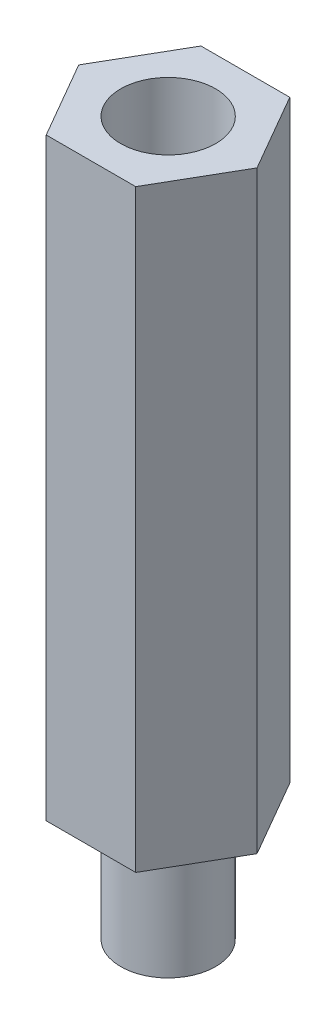
from build123d import *

# Parameters (mm, degrees)
SKETCH_1_R      = 4
EXTRUDE_1_DEPTH = 50
SKETCH_2_R      = 4
EXTRUDE_2_DEPTH = 10


with BuildPart() as part:
    # 草图1 → 凸台-拉伸1 (new body)
    with BuildSketch(Plane(origin=(0, 0, 0), x_dir=(1, 0, 0), z_dir=(0, 1, 0))):
        Polygon((-3.041910015, 3.990808824), (4.434714707, 3.990808824), (8.201955845, -2.534244233), (4.463643484, -9.009191176), (-3.070838793, -9.009191176), (-6.809151154, -2.534244233), align=None)
        with Locations((0.696402346, -2.509191176)):
            Circle(SKETCH_1_R, mode=Mode.SUBTRACT)
    extrude(amount=EXTRUDE_1_DEPTH)


with BuildPart() as body_2:
    # 草图2 → 凸台-拉伸2 (new body)
    with BuildSketch(Plane.XZ):
        with Locations((0.696402346, 2.509191176)):
            Circle(SKETCH_2_R)
    extrude(amount=EXTRUDE_2_DEPTH)


solid = Compound([part.part, body_2.part])
